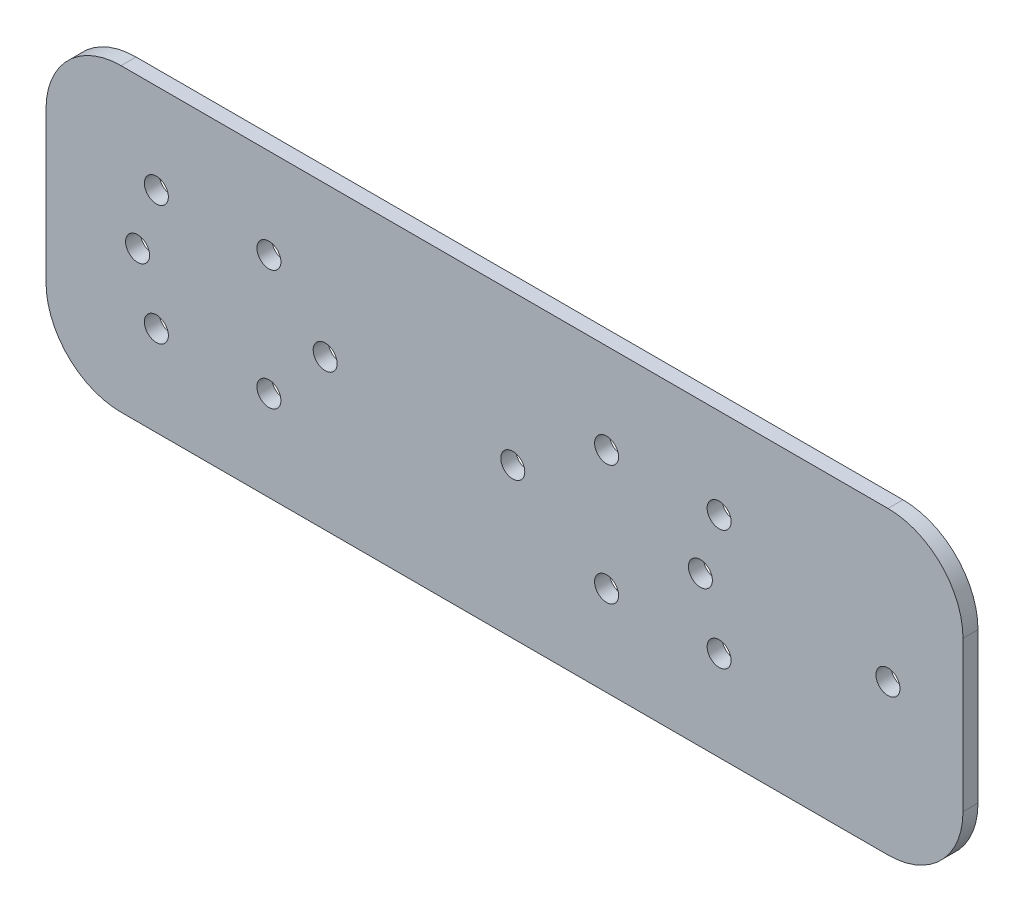
from build123d import *

# Parameters (mm, degrees)
SKETCH_1_W          = 140
SKETCH_1_H          = 40
SKETCH_1_R          = 1.6
EXTRUDE_1_DEPTH     = 2
FILLET_1_R          = 10
SKETCH_2_W          = 24.439336454
SKETCH_2_H          = 40
CUT_EXTRUDE_1_DEPTH = 10
FILLET_2_R          = 10


with BuildPart() as part:
    # 草图1 → 凸台-拉伸1 (new body)
    with BuildSketch(Plane.XY):
        Rectangle(SKETCH_1_W, SKETCH_1_H)
        with Locations((37.5, 8)):
            Circle(SKETCH_1_R, mode=Mode.SUBTRACT)
        with Locations((37.5, -8)):
            Circle(SKETCH_1_R, mode=Mode.SUBTRACT)
        with Locations((22.5, -8)):
            Circle(SKETCH_1_R, mode=Mode.SUBTRACT)
        with Locations((22.5, 8)):
            Circle(SKETCH_1_R, mode=Mode.SUBTRACT)
        with Locations((-22.5, -8)):
            Circle(SKETCH_1_R, mode=Mode.SUBTRACT)
        with Locations((-37.5, -8)):
            Circle(SKETCH_1_R, mode=Mode.SUBTRACT)
        with Locations((-22.5, 8)):
            Circle(SKETCH_1_R, mode=Mode.SUBTRACT)
        with Locations((-37.5, 8)):
            Circle(SKETCH_1_R, mode=Mode.SUBTRACT)
        with Locations((60, 0)):
            Circle(SKETCH_1_R, mode=Mode.SUBTRACT)
        with Locations((35, 0)):
            Circle(SKETCH_1_R, mode=Mode.SUBTRACT)
        with Locations((10, 0)):
            Circle(SKETCH_1_R, mode=Mode.SUBTRACT)
        with Locations((-15, 0)):
            Circle(SKETCH_1_R, mode=Mode.SUBTRACT)
        with Locations((-40, 0)):
            Circle(SKETCH_1_R, mode=Mode.SUBTRACT)
    extrude(amount=EXTRUDE_1_DEPTH)

    # 圆角1
    fillet_1_edges = [part.edges().sort_by_distance(p)[0] for p in [
        (70, -20, 1),
        (-70, -20, 1),
        (-70, 20, 1),
        (70, 20, 1),
    ]]
    fillet(fillet_1_edges, radius=FILLET_1_R)

    # 草图2 → 切除-拉伸1 (cut)
    with BuildSketch(Plane.XY.offset(2)):
        with Locations((-64.426426614, 0)):
            Rectangle(SKETCH_2_W, SKETCH_2_H)
    extrude(amount=-CUT_EXTRUDE_1_DEPTH, mode=Mode.SUBTRACT)

    # 圆角2
    fillet_2_edges = [part.edges().sort_by_distance(p)[0] for p in [
        (-52.206758387, 20, 1),
        (-52.206758387, -20, 1),
    ]]
    fillet(fillet_2_edges, radius=FILLET_2_R)


solid = part.part
